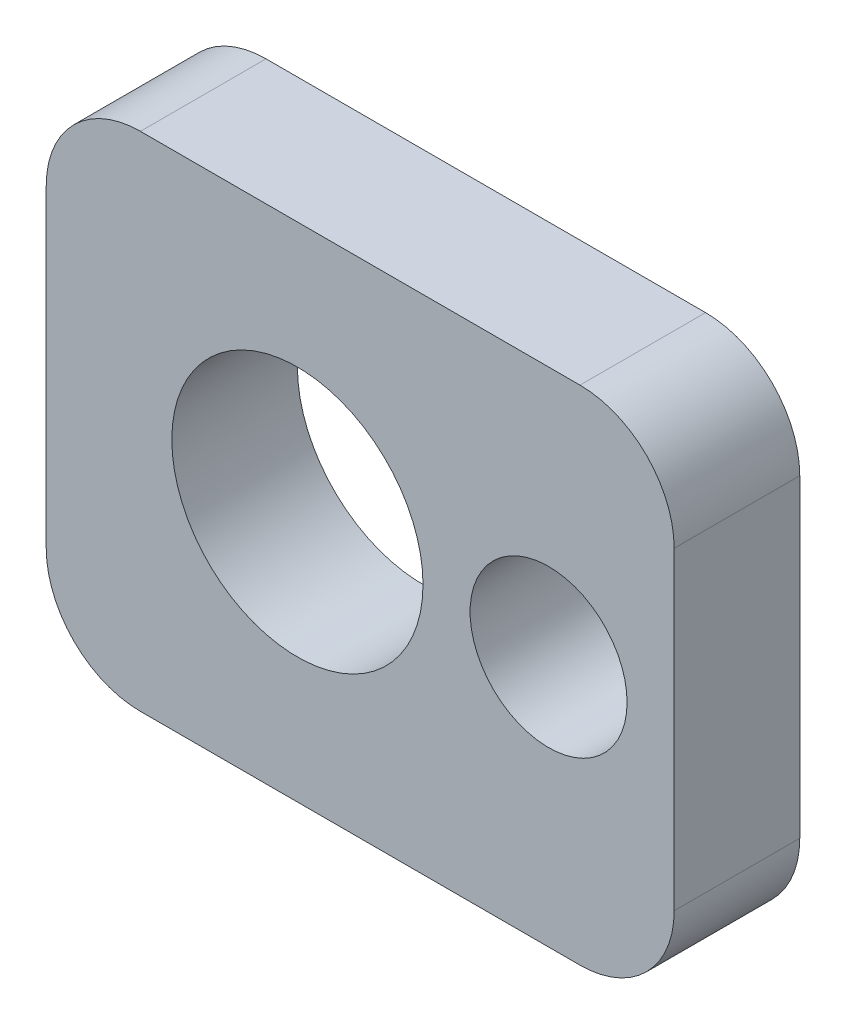
from build123d import *

# Parameters (mm, degrees)
BOSS_EXTRUDE1_DEPTH     = 20
SKETCH3_R               = 20
CUT_EXTRUDE2_DEPTH      = 1
CUT_EXTRUDE2_DEPTH_BACK = 21
SKETCH4_R               = 12.5
CUT_EXTRUDE3_DEPTH      = 21


with BuildPart() as part:
    # Sketch1 → Boss-Extrude1 (new body)
    with BuildSketch(Plane.XY):
        with BuildLine():
            Line((35, -40), (-35, -40))
            ThreePointArc((-35, -40), (-45.606601718, -35.606601718), (-50, -25))
            Line((-50, -25), (-50, 25))
            ThreePointArc((-50, 25), (-45.606601718, 35.606601718), (-35, 40))
            Line((-35, 40), (35, 40))
            ThreePointArc((35, 40), (45.606601718, 35.606601718), (50, 25))
            Line((50, 25), (50, -25))
            ThreePointArc((50, -25), (45.606601718, -35.606601718), (35, -40))
        make_face()
    extrude(amount=BOSS_EXTRUDE1_DEPTH)

    # Sketch3 → Cut-Extrude2 (cut, two sides)
    with BuildSketch(Plane.XY.offset(20)) as cut_extrude2_sk:
        with Locations((-10, 0)):
            Circle(SKETCH3_R)
    extrude(amount=CUT_EXTRUDE2_DEPTH, mode=Mode.SUBTRACT)
    extrude(cut_extrude2_sk.sketch, amount=-CUT_EXTRUDE2_DEPTH_BACK, mode=Mode.SUBTRACT)

    # Sketch4 → Cut-Extrude3 (cut, through all)
    with BuildSketch(Plane.XY.offset(20)):
        with Locations((30, 0)):
            Circle(SKETCH4_R)
    extrude(amount=-CUT_EXTRUDE3_DEPTH, mode=Mode.SUBTRACT)


solid = part.part
